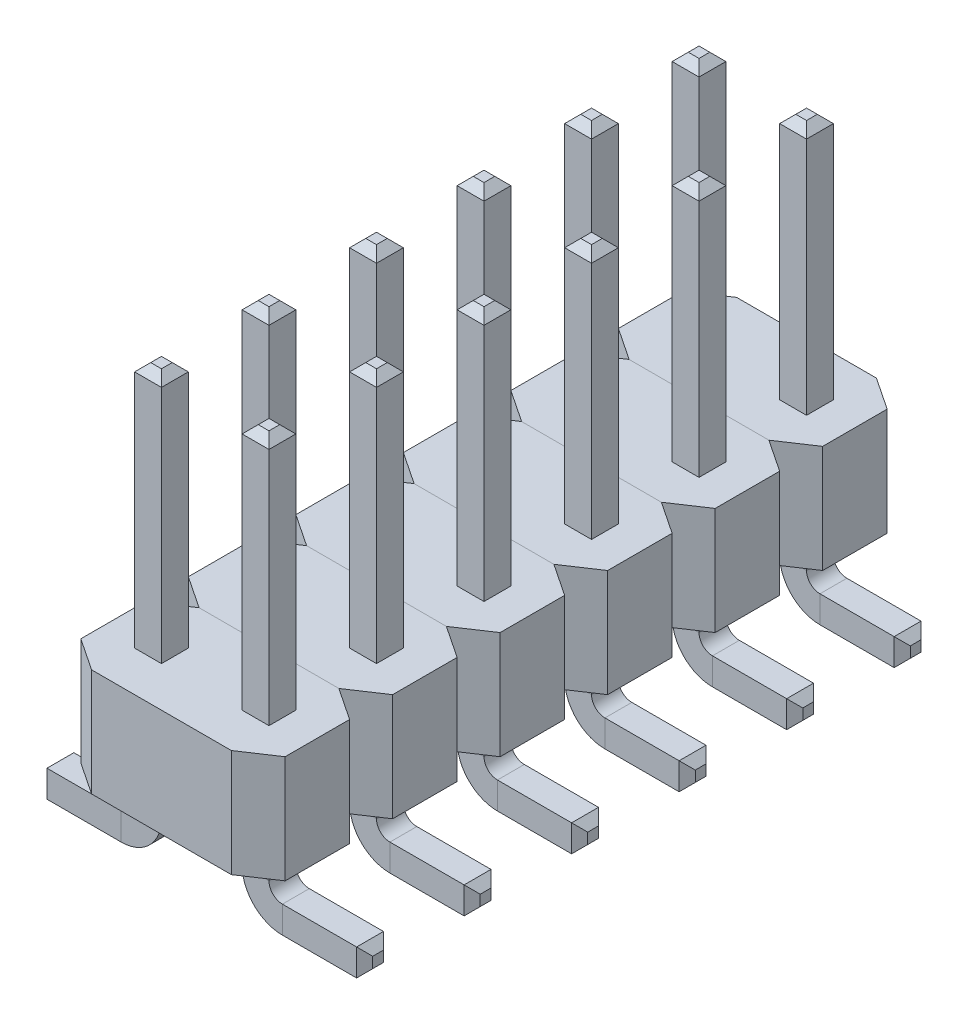
from build123d import *

# Parameters (mm, degrees)
BOSS_EXTRUDE2_DEPTH = 2.54
SKETCH5_W           = 0.635
SKETCH5_H           = 0.635
SKETCH6_W           = 0.635
SKETCH6_H           = 0.635
CHAMFER1_SIZE       = 0.1905
LPATTERN1_COUNT     = 6
LPATTERN1_PITCH     = 2.54


with BuildPart() as part:
    # Sketch1 → Boss-Extrude2 (new body)
    with BuildSketch(Plane(origin=(0, 0, 0), x_dir=(1, 0, 0), z_dir=(0, 1, 0))):
        Polygon((-2.413, -0.762), (-1.651, -1.27), (1.651, -1.27), (2.413, -0.762), (2.413, 0.762), (1.651, 1.27), (-1.651, 1.27), (-2.413, 0.762), align=None)
    extrude(amount=BOSS_EXTRUDE2_DEPTH)

    # Sweep5: sweep along a path in Sketch2
    with BuildLine(Plane.XY) as sweep5_path:
        Line((-1.27, 8.382), (-1.27, 2.54))
        Line((-1.27, 2.54), (-1.27, -0.635))
        ThreePointArc((-1.27, -0.635), (-1.455987194, -1.084012806), (-1.905, -1.27))
        Line((-1.905, -1.27), (-3.8481, -1.27))
    # Sketch5 → Sweep5 (sweep)
    with BuildSketch(Plane(origin=(0, 8.382, 0), x_dir=(1, 0, 0), z_dir=(0, 1, 0))):
        with Locations((-1.27, 0)):
            Rectangle(SKETCH5_W, SKETCH5_H)
    sweep(path=sweep5_path.line)

    # Sweep6: sweep along a path in Sketch7
    with BuildLine(Plane.XY) as sweep6_path:
        Line((1.27, 8.382), (1.27, 2.54))
        Line((1.27, 2.54), (1.27, -0.635))
        ThreePointArc((1.27, -0.635), (1.455987194, -1.084012806), (1.905, -1.27))
        Line((1.905, -1.27), (3.8481, -1.27))
    # Sketch6 → Sweep6 (sweep)
    with BuildSketch(Plane(origin=(0, 8.382, 0), x_dir=(1, 0, 0), z_dir=(0, 1, 0))):
        with Locations((1.27, 0)):
            Rectangle(SKETCH6_W, SKETCH6_H)
    sweep(path=sweep6_path.line)

    # Chamfer1
    chamfer1_edges = [part.edges().sort_by_distance(p)[0] for p in [
        (-3.8481, -1.27, -0.3175),
        (-3.8481, -1.5875, 0),
        (-3.8481, -1.27, 0.3175),
        (-3.8481, -0.9525, 0),
        (-1.27, 8.382, -0.3175),
        (-0.9525, 8.382, 0),
        (-1.27, 8.382, 0.3175),
        (-1.5875, 8.382, 0),
        (1.5875, 8.382, 0),
        (1.27, 8.382, -0.3175),
        (0.9525, 8.382, 0),
        (1.27, 8.382, 0.3175),
        (3.8481, -0.9525, 0),
        (3.8481, -1.27, -0.3175),
        (3.8481, -1.5875, 0),
        (3.8481, -1.27, 0.3175),
    ]]
    chamfer(chamfer1_edges, length=CHAMFER1_SIZE)


with BuildPart() as lpattern1_1:
    # LPattern1: pattern copy
    add(part.part.moved(Location(Vector(0, 0, -1) * (1 * LPATTERN1_PITCH))))


with BuildPart() as lpattern1_2:
    # LPattern1: pattern copy
    add(part.part.moved(Location(Vector(0, 0, -1) * (2 * LPATTERN1_PITCH))))


with BuildPart() as lpattern1_3:
    # LPattern1: pattern copy
    add(part.part.moved(Location(Vector(0, 0, -1) * (3 * LPATTERN1_PITCH))))


with BuildPart() as lpattern1_4:
    # LPattern1: pattern copy
    add(part.part.moved(Location(Vector(0, 0, -1) * (4 * LPATTERN1_PITCH))))


with BuildPart() as lpattern1_5:
    # LPattern1: pattern copy
    add(part.part.moved(Location(Vector(0, 0, -1) * (5 * LPATTERN1_PITCH))))


solid = Compound([part.part, lpattern1_1.part, lpattern1_2.part, lpattern1_3.part, lpattern1_4.part, lpattern1_5.part])
